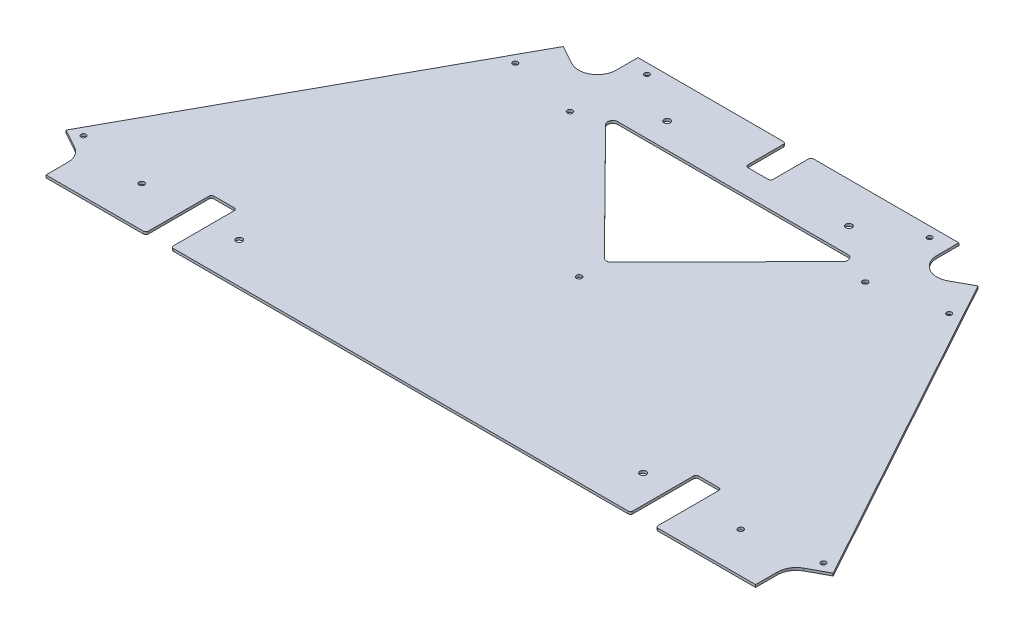
from build123d import *

# Parameters (mm, degrees)
BOSS_EXTRUDE1_DEPTH            = 3.175
SKETCH2_W                      = 31.75
SKETCH2_H                      = 82.55
CUT_EXTRUDE1_DEPTH             = 4.175
FILLET1_R                      = 3.175
F_1_4_0_25_DIAMETER_HOLE1_D    = 6.35
F_1_4_CLEARANCE_HOLE1_D        = 6.7564
F_5_16_0_3125_DIAMETER_HOLE1_D = 7.9375
CUT_EXTRUDE2_DEPTH             = 4.175
FILLET2_R                      = 6.35
SKETCH12_W                     = 31.75
SKETCH12_H                     = 50.8
CUT_EXTRUDE3_DEPTH             = 4.175
FILLET3_R                      = 3.175


with BuildPart() as part:
    # Sketch1 → Boss-Extrude1 (new body)
    with BuildSketch(Plane(origin=(0, 0, 0), x_dir=(1, 0, 0), z_dir=(0, 1, 0))):
        with BuildLine():
            Line((-260.839523021, 465.231358695), (-482.578348021, 61.34030281))
            Line((-482.578348021, 61.34030281), (-458.5319125, 48.13865281))
            ThreePointArc((-458.5319125, 48.13865281), (-449.57100781, 39.462418136), (-446.278, 27.432))
            Line((-446.278, 27.432), (-446.278, 0))
            Line((-446.278, 0), (446.278, 0))
            Line((446.278, 0), (446.278, 27.432))
            ThreePointArc((446.278, 27.432), (449.57100781, 39.462418136), (458.5319125, 48.13865281))
            Line((458.5319125, 48.13865281), (482.578348021, 61.34030281))
            Line((482.578348021, 61.34030281), (260.839523021, 465.231358695))
            Line((260.839523021, 465.231358695), (236.7930875, 452.029708695))
            ThreePointArc((236.7930875, 452.029708695), (213.394581864, 452.407369315), (201.803, 472.736361505))
            Line((201.803, 472.736361505), (201.803, 500.168361505))
            Line((201.803, 500.168361505), (-201.803, 500.168361505))
            Line((-201.803, 500.168361505), (-201.803, 472.736361505))
            ThreePointArc((-201.803, 472.736361505), (-213.394581864, 452.407369315), (-236.7930875, 452.029708695))
            Line((-236.7930875, 452.029708695), (-260.839523021, 465.231358695))
        make_face()
    extrude(amount=BOSS_EXTRUDE1_DEPTH)

    # Sketch2 → Cut-Extrude1 (cut, through all)
    with BuildSketch(Plane(origin=(0, 3.175, 0), x_dir=(1, 0, 0), z_dir=(0, 1, 0))):
        with Locations((-304.8, 41.275)):
            Rectangle(SKETCH2_W, SKETCH2_H)
        with Locations((304.8, 41.275)):
            Rectangle(SKETCH2_W, SKETCH2_H)
    extrude(amount=-CUT_EXTRUDE1_DEPTH, mode=Mode.SUBTRACT)

    # Fillet1
    fillet1_edges = [part.edges().sort_by_distance(p)[0] for p in [
        (-288.925, 1.5875, -82.55),
        (-288.925, 1.5875, 0),
        (-320.675, 1.5875, 0),
        (-320.675, 1.5875, -82.55),
        (288.925, 1.5875, 0),
        (288.925, 1.5875, -82.55),
        (320.675, 1.5875, -82.55),
        (320.675, 1.5875, 0),
    ]]
    fillet(fillet1_edges, radius=FILLET1_R)

    # 1/4 (0.25) Diameter Hole1 (through all)
    with Locations(Plane(origin=(0, 3.175, 0), x_dir=(1, 0, 0), z_dir=(0, 1, 0))):
        with Locations((-465.394777961, 66.250083744), (-272.870715461, 416.927268429), (-177.8, 487.468361505), (465.394777961, 66.250083744), (272.870715461, 416.927268429), (177.8, 487.468361505)):
            Hole(F_1_4_0_25_DIAMETER_HOLE1_D / 2)

    # 1/4 Clearance Hole1 (through all)
    with Locations(Plane(origin=(0, 3.175, 0), x_dir=(1, 0, 0), z_dir=(0, 1, 0))):
        with Locations((0, 224.282), (-376.682, 50.8), (-185.674, 398.526), (376.682, 50.8), (185.674, 398.526)):
            Hole(F_1_4_CLEARANCE_HOLE1_D / 2)

    # 5/16 (0.3125) Diameter Hole1 (through all)
    with Locations(Plane(origin=(0, 3.175, 0), x_dir=(1, 0, 0), z_dir=(0, 1, 0))):
        with Locations((-254, 50.8), (-114.3, 449.368361505), (254, 50.8), (114.3, 449.368361505)):
            Hole(F_5_16_0_3125_DIAMETER_HOLE1_D / 2)

    # Sketch11 → Cut-Extrude2 (cut, through all)
    with BuildSketch(Plane(origin=(0, 3.175, 0), x_dir=(1, 0, 0), z_dir=(0, 1, 0))):
        Polygon((0, 256.032), (159.899523893, 417.618361505), (-159.899523893, 417.618361505), align=None)
    extrude(amount=-CUT_EXTRUDE2_DEPTH, mode=Mode.SUBTRACT)

    # Fillet2
    fillet2_edges = [part.edges().sort_by_distance(p)[0] for p in [
        (0, 1.5875, -256.032),
        (-159.899523893, 1.5875, -417.618361505),
        (159.899523893, 1.5875, -417.618361505),
    ]]
    fillet(fillet2_edges, radius=FILLET2_R)

    # Sketch12 → Cut-Extrude3 (cut, through all)
    with BuildSketch(Plane(origin=(0, 3.175, 0), x_dir=(1, 0, 0), z_dir=(0, 1, 0))):
        with Locations((0, 474.768361505)):
            Rectangle(SKETCH12_W, SKETCH12_H)
    extrude(amount=-CUT_EXTRUDE3_DEPTH, mode=Mode.SUBTRACT)

    # Fillet3
    fillet3_edges = [part.edges().sort_by_distance(p)[0] for p in [
        (-15.875, 1.5875, -449.368361505),
        (-15.875, 1.5875, -500.168361505),
        (15.875, 1.5875, -500.168361505),
        (15.875, 1.5875, -449.368361505),
    ]]
    fillet(fillet3_edges, radius=FILLET3_R)


solid = part.part
